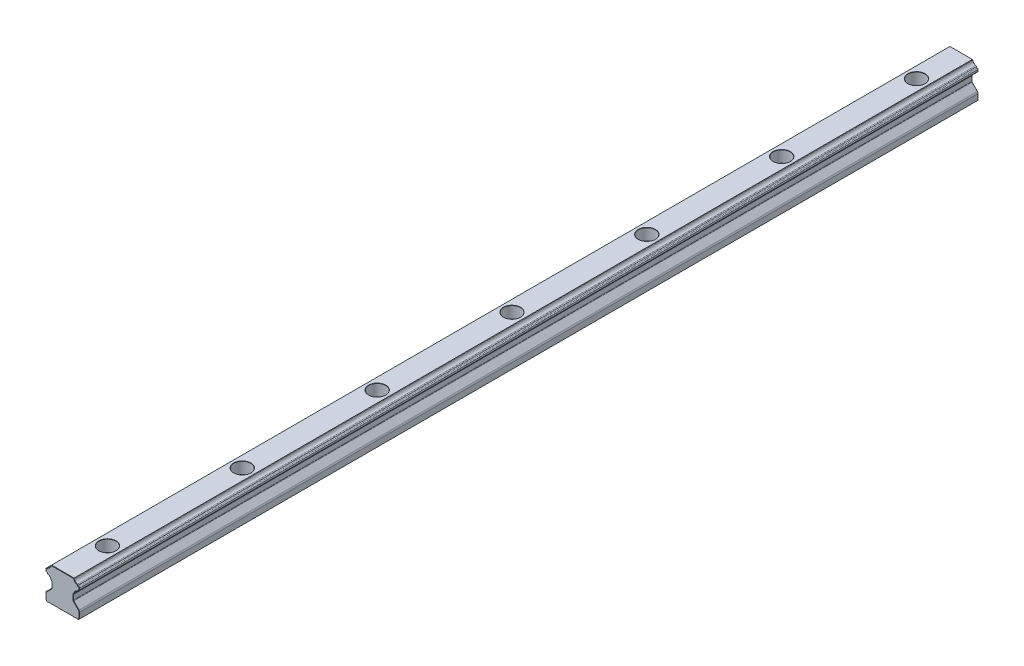
from build123d import *

# Parameters (mm, degrees)
BODY_DEPTH                                 = 400
AESTHETIC_CHAMFER_SIZE                     = 0.15
PRODUCTION_FILLET_R                        = 0.1
MOUNTING_HOLES_PATTERN_COUNT               = 7
MOUNTING_HOLES_PATTERN_PITCH               = 60
PRODUCTION_FILLET_OF_MOUNTING_HOLES_PATT_R = 0.1


with BuildPart() as part:
    # Rail Profile → Body (new body)
    with BuildSketch(Plane.XY):
        with BuildLine():
            Line((-7, 0), (7, 0))
            Line((7, 0), (7.5, 0.5))
            Line((7.5, 0.5), (7.5, 3.085786438))
            ThreePointArc((7.5, 3.085786438), (7.423879533, 3.46846987), (7.207106781, 3.792893219))
            Line((7.207106781, 3.792893219), (4.867157288, 6.132842712))
            ThreePointArc((4.867157288, 6.132842712), (4.780448187, 6.262612052), (4.75, 6.415685425))
            Line((4.75, 6.415685425), (4.75, 8.584314575))
            ThreePointArc((4.75, 8.584314575), (4.780448187, 8.737387948), (4.867157288, 8.867157288))
            Line((4.867157288, 8.867157288), (5.062965362, 9.062965362))
            ThreePointArc((5.062965362, 9.062965362), (5.134996734, 9.161242682), (5.17409812, 9.27664646))
            ThreePointArc((5.17409812, 9.27664646), (5.61862915, 10.13137085), (6.47335354, 10.57590188))
            ThreePointArc((6.47335354, 10.57590188), (6.694124352, 10.694306692), (6.801170165, 10.920803148))
            ThreePointArc((6.801170165, 10.920803148), (6.915305692, 11.154571658), (7.149074202, 11.268707185))
            ThreePointArc((7.149074202, 11.268707185), (7.399691242, 11.400760606), (7.5, 11.665685425))
            Line((7.5, 11.665685425), (7.5, 12.334314575))
            ThreePointArc((7.5, 12.334314575), (7.399691242, 12.599239394), (7.149074202, 12.731292815))
            ThreePointArc((7.149074202, 12.731292815), (6.915305692, 12.845428342), (6.801170165, 13.079196852))
            ThreePointArc((6.801170165, 13.079196852), (6.694124352, 13.305693308), (6.47335354, 13.42409812))
            ThreePointArc((6.47335354, 13.42409812), (5.61862915, 13.86862915), (5.17409812, 14.72335354))
            ThreePointArc((5.17409812, 14.72335354), (5.134996734, 14.838757318), (5.062965362, 14.937034638))
            Line((5.062965362, 14.937034638), (5, 15))
            Line((5, 15), (-5, 15))
            Line((-5, 15), (-5.062965362, 14.937034638))
            ThreePointArc((-5.062965362, 14.937034638), (-5.134996734, 14.838757318), (-5.17409812, 14.72335354))
            ThreePointArc((-5.17409812, 14.72335354), (-5.61862915, 13.86862915), (-6.47335354, 13.42409812))
            ThreePointArc((-6.47335354, 13.42409812), (-6.694124352, 13.305693308), (-6.801170165, 13.079196852))
            ThreePointArc((-6.801170165, 13.079196852), (-6.915305692, 12.845428342), (-7.149074202, 12.731292815))
            ThreePointArc((-7.149074202, 12.731292815), (-7.399691242, 12.599239394), (-7.5, 12.334314575))
            Line((-7.5, 12.334314575), (-7.5, 11.665685425))
            ThreePointArc((-7.5, 11.665685425), (-7.399691242, 11.400760606), (-7.149074202, 11.268707185))
            ThreePointArc((-7.149074202, 11.268707185), (-6.915305692, 11.154571658), (-6.801170165, 10.920803148))
            ThreePointArc((-6.801170165, 10.920803148), (-6.694124352, 10.694306692), (-6.47335354, 10.57590188))
            ThreePointArc((-6.47335354, 10.57590188), (-5.61862915, 10.13137085), (-5.17409812, 9.27664646))
            ThreePointArc((-5.17409812, 9.27664646), (-5.134996734, 9.161242682), (-5.062965362, 9.062965362))
            Line((-5.062965362, 9.062965362), (-4.867157288, 8.867157288))
            ThreePointArc((-4.867157288, 8.867157288), (-4.780448187, 8.737387948), (-4.75, 8.584314575))
            Line((-4.75, 8.584314575), (-4.75, 6.415685425))
            ThreePointArc((-4.75, 6.415685425), (-4.780448187, 6.262612052), (-4.867157288, 6.132842712))
            Line((-4.867157288, 6.132842712), (-7.207106781, 3.792893219))
            ThreePointArc((-7.207106781, 3.792893219), (-7.423879533, 3.46846987), (-7.5, 3.085786438))
            Line((-7.5, 3.085786438), (-7.5, 0.5))
            Line((-7.5, 0.5), (-7, 0))
        make_face()
    extrude(amount=-BODY_DEPTH)

    # Aesthetic Chamfer
    aesthetic_chamfer_edges = [part.edges().sort_by_distance(p)[0] for p in [
        (7.423879533, 3.46846987, -400),
        (-5.134996734, 9.161242682, -400),
        (-4.965061325, 8.965061325, -400),
        (-4.780448187, 8.737387948, -400),
        (-4.75, 7.5, -400),
        (-4.780448187, 6.262612052, -400),
        (-6.037132034, 4.962867966, -400),
        (-7.423879533, 3.46846987, -400),
        (-7.5, 1.792893219, -400),
        (-7.25, 0.25, -400),
        (0, 0, -400),
        (6.037132034, 4.962867966, -400),
        (4.780448187, 6.262612052, -400),
        (4.75, 7.5, -400),
        (4.780448187, 8.737387948, -400),
        (4.965061325, 8.965061325, -400),
        (5.134996734, 9.161242682, -400),
        (5.61862915, 10.13137085, -400),
        (6.694124352, 10.694306692, -400),
        (0, 0, 0),
        (-7.25, 0.25, 0),
        (-7.5, 1.792893219, 0),
        (-7.423879533, 3.46846987, 0),
        (-6.037132034, 4.962867966, 0),
        (-4.780448187, 6.262612052, 0),
        (6.915305692, 11.154571658, -400),
        (-4.75, 7.5, 0),
        (-4.780448187, 8.737387948, 0),
        (-4.965061325, 8.965061325, 0),
        (-5.134996734, 9.161242682, 0),
        (-5.61862915, 10.13137085, 0),
        (-6.694124352, 10.694306692, 0),
        (-6.915305692, 11.154571658, 0),
        (7.25, 0.25, -400),
        (7.399691242, 11.400760606, -400),
        (-7.399691242, 11.400760606, 0),
        (-7.5, 12, 0),
        (-7.399691242, 12.599239394, 0),
        (-6.915305692, 12.845428342, 0),
        (-6.694124352, 13.305693308, 0),
        (-5.61862915, 13.86862915, 0),
        (-5.134996734, 14.838757318, 0),
        (-5.031482681, 14.968517319, 0),
        (7.5, 12, -400),
        (0, 15, 0),
        (5.031482681, 14.968517319, 0),
        (5.134996734, 14.838757318, 0),
        (5.61862915, 13.86862915, 0),
        (6.694124352, 13.305693308, 0),
        (6.915305692, 12.845428342, 0),
        (7.399691242, 12.599239394, 0),
        (7.399691242, 12.599239394, -400),
        (7.5, 12, 0),
        (7.399691242, 11.400760606, 0),
        (6.915305692, 11.154571658, 0),
        (6.694124352, 10.694306692, 0),
        (5.61862915, 10.13137085, 0),
        (5.134996734, 9.161242682, 0),
        (4.965061325, 8.965061325, 0),
        (4.780448187, 8.737387948, 0),
        (6.915305692, 12.845428342, -400),
        (4.75, 7.5, 0),
        (4.780448187, 6.262612052, 0),
        (6.037132034, 4.962867966, 0),
        (7.423879533, 3.46846987, 0),
        (7.5, 1.792893219, 0),
        (7.25, 0.25, 0),
        (6.694124352, 13.305693308, -400),
        (5.61862915, 13.86862915, -400),
        (5.134996734, 14.838757318, -400),
        (5.031482681, 14.968517319, -400),
        (0, 15, -400),
        (-5.031482681, 14.968517319, -400),
        (7.5, 1.792893219, -400),
        (-5.134996734, 14.838757318, -400),
        (-5.61862915, 13.86862915, -400),
        (-6.694124352, 13.305693308, -400),
        (-6.915305692, 12.845428342, -400),
        (-7.399691242, 12.599239394, -400),
        (-7.5, 12, -400),
        (-7.399691242, 11.400760606, -400),
        (-6.915305692, 11.154571658, -400),
        (-6.694124352, 10.694306692, -400),
        (-5.61862915, 10.13137085, -400),
    ]]
    chamfer(aesthetic_chamfer_edges, length=AESTHETIC_CHAMFER_SIZE)

    # Sketch1 → Mounting Hole (revolve, cut)
    with BuildSketch(Plane(origin=(0, 15, -20), x_dir=(0, 0, 1), z_dir=(1, 0, 0))):
        Polygon((0, 0), (0, 15), (2.35, 15), (2.25, 14.9), (2.25, 5.4), (2.35, 5.3), (3.75, 5.3), (3.75, 0.1), (3.85, 0), align=None)
    mounting_hole = revolve(axis=Axis((0, 21.35, -20), (0, -1, 0)), mode=Mode.SUBTRACT)

    # Production Fillet
    production_fillet_edges = [part.edges().sort_by_distance(p)[0] for p in [
        (0, 9.7, -23.75),
    ]]
    fillet(production_fillet_edges, radius=PRODUCTION_FILLET_R)

    # Mounting Holes Pattern: Mounting Hole ×7
    with Locations(*[(0, 0, -i * MOUNTING_HOLES_PATTERN_PITCH) for i in range(1, MOUNTING_HOLES_PATTERN_COUNT)]):
        add(mounting_hole, mode=Mode.SUBTRACT)

    # Production Fillet of Mounting Holes Patt
    production_fillet_of_mounting_holes_patt_edges = [part.edges().sort_by_distance(p)[0] for p in [
        (0, 9.7, -83.75),
        (0, 9.7, -143.75),
        (0, 9.7, -203.75),
        (0, 9.7, -263.75),
        (0, 9.7, -323.75),
        (0, 9.7, -383.75),
    ]]
    fillet(production_fillet_of_mounting_holes_patt_edges, radius=PRODUCTION_FILLET_OF_MOUNTING_HOLES_PATT_R)


solid = part.part
